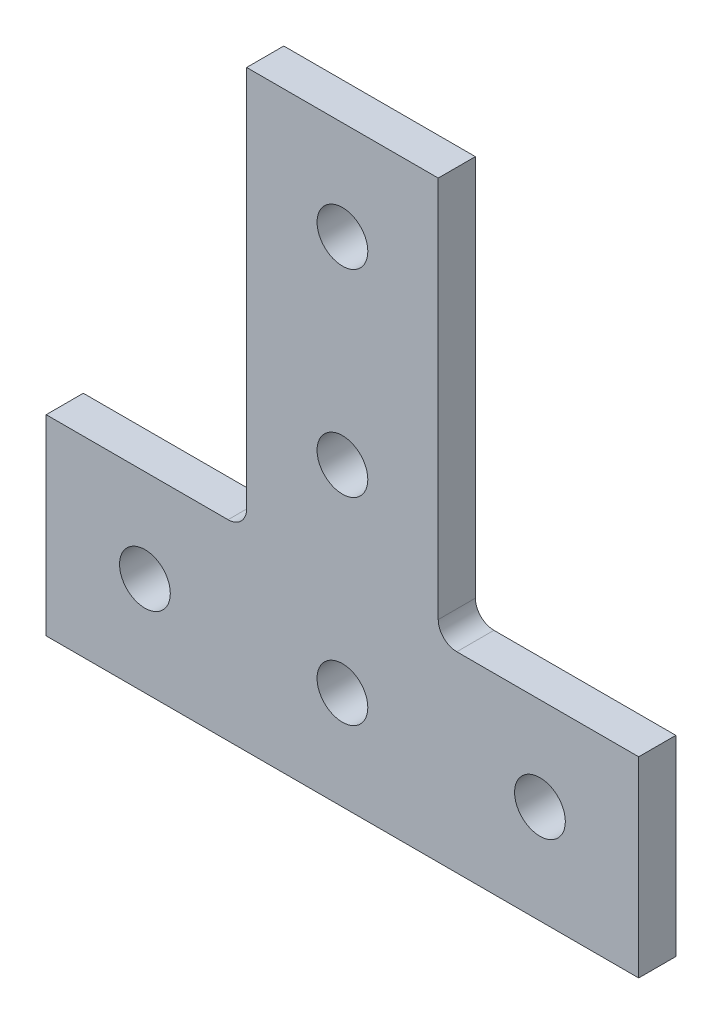
from build123d import *

# Parameters (mm, degrees)
SKETCH1_R           = 3.2639
BOSS_EXTRUDE1_DEPTH = 4.7752


with BuildPart() as part:
    # Sketch1 → Boss-Extrude1 (new body)
    with BuildSketch(Plane.XY):
        with BuildLine():
            Line((-38.1, 0), (38.1, 0))
            Line((38.1, 0), (38.1, 24.638))
            Line((38.1, 24.638), (14.7066, 24.638))
            ThreePointArc((14.7066, 24.638), (13.018311849, 25.337311849), (12.319, 27.0256))
            Line((12.319, 27.0256), (12.319, 76.2))
            Line((12.319, 76.2), (-12.319, 76.2))
            Line((-12.319, 76.2), (-12.319, 27.0256))
            ThreePointArc((-12.319, 27.0256), (-13.018311849, 25.337311849), (-14.7066, 24.638))
            Line((-14.7066, 24.638), (-38.1, 24.638))
            Line((-38.1, 24.638), (-38.1, 0))
        make_face()
        with Locations((25.4, 12.7)):
            Circle(SKETCH1_R, mode=Mode.SUBTRACT)
        with Locations((0, 38.1)):
            Circle(SKETCH1_R, mode=Mode.SUBTRACT)
        with Locations((0, 63.5)):
            Circle(SKETCH1_R, mode=Mode.SUBTRACT)
        with Locations((0, 12.7)):
            Circle(SKETCH1_R, mode=Mode.SUBTRACT)
        with Locations((-25.4, 12.7)):
            Circle(SKETCH1_R, mode=Mode.SUBTRACT)
    extrude(amount=BOSS_EXTRUDE1_DEPTH)


solid = part.part
